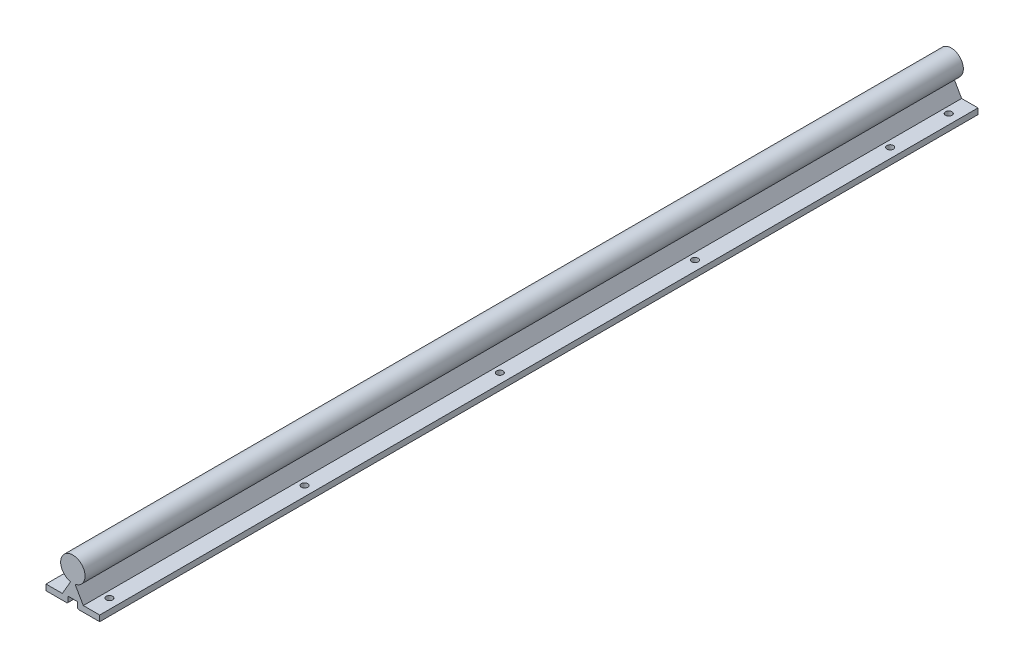
from build123d import *

# Parameters (mm, degrees)
SKETCH1_R               = 12.5
BOSS_EXTRUDE1_DEPTH     = 900
CHAMFER1_SIZE           = 1
SKETCH2_R               = 3.3
CUT_EXTRUDE1_DEPTH      = 40.5
CUT_EXTRUDE1_DEPTH_BACK = 7


with BuildPart() as part:
    # Sketch1 → Boss-Extrude1 (new body)
    with BuildSketch(Plane.XY):
        with Locations((0, 33)):
            Circle(SKETCH1_R)
        Polygon((-27.5, 0), (-4.75, 0), (-4.75, 6.5), (4.75, 6.5), (4.75, 0), (27.5, 0), (27.5, 6), (10.75, 6), (2.089745962, 21), (-2.089745962, 21), (-10.75, 6), (-27.5, 6), align=None)
    extrude(amount=-BOSS_EXTRUDE1_DEPTH)

    # Chamfer1
    chamfer1_edges = [part.edges().sort_by_distance(p)[0] for p in [
        (4.75, 0, -450),
        (-4.75, 0, -450),
    ]]
    chamfer(chamfer1_edges, length=CHAMFER1_SIZE)

    # Sketch2 → Cut-Extrude1 (cut, two sides)
    with BuildSketch(Plane(origin=(0, 6, 0), x_dir=(1, 0, 0), z_dir=(0, 1, 0))) as cut_extrude1_sk:
        with Locations((17.5, 20)):
            Circle(SKETCH2_R)
        with Locations((-17.5, 20)):
            Circle(SKETCH2_R)
        with Locations((-17.5, 220)):
            Circle(SKETCH2_R)
        with Locations((17.5, 220)):
            Circle(SKETCH2_R)
        with Locations((-17.5, 420)):
            Circle(SKETCH2_R)
        with Locations((17.5, 420)):
            Circle(SKETCH2_R)
        with Locations((-17.5, 620)):
            Circle(SKETCH2_R)
        with Locations((17.5, 620)):
            Circle(SKETCH2_R)
        with Locations((-17.5, 820)):
            Circle(SKETCH2_R)
        with Locations((17.5, 820)):
            Circle(SKETCH2_R)
        with Locations((-17.5, 1020)):
            Circle(SKETCH2_R)
        with Locations((17.5, 1020)):
            Circle(SKETCH2_R)
        with Locations((-17.5, 1220)):
            Circle(SKETCH2_R)
        with Locations((17.5, 1220)):
            Circle(SKETCH2_R)
        with Locations((-17.5, 1420)):
            Circle(SKETCH2_R)
        with Locations((17.5, 1420)):
            Circle(SKETCH2_R)
        with Locations((-17.5, 1620)):
            Circle(SKETCH2_R)
        with Locations((17.5, 1620)):
            Circle(SKETCH2_R)
        with Locations((17.5, 880)):
            Circle(SKETCH2_R)
        with Locations((-17.5, 880)):
            Circle(SKETCH2_R)
    extrude(amount=CUT_EXTRUDE1_DEPTH, mode=Mode.SUBTRACT)
    extrude(cut_extrude1_sk.sketch, amount=-CUT_EXTRUDE1_DEPTH_BACK, mode=Mode.SUBTRACT)


solid = part.part
